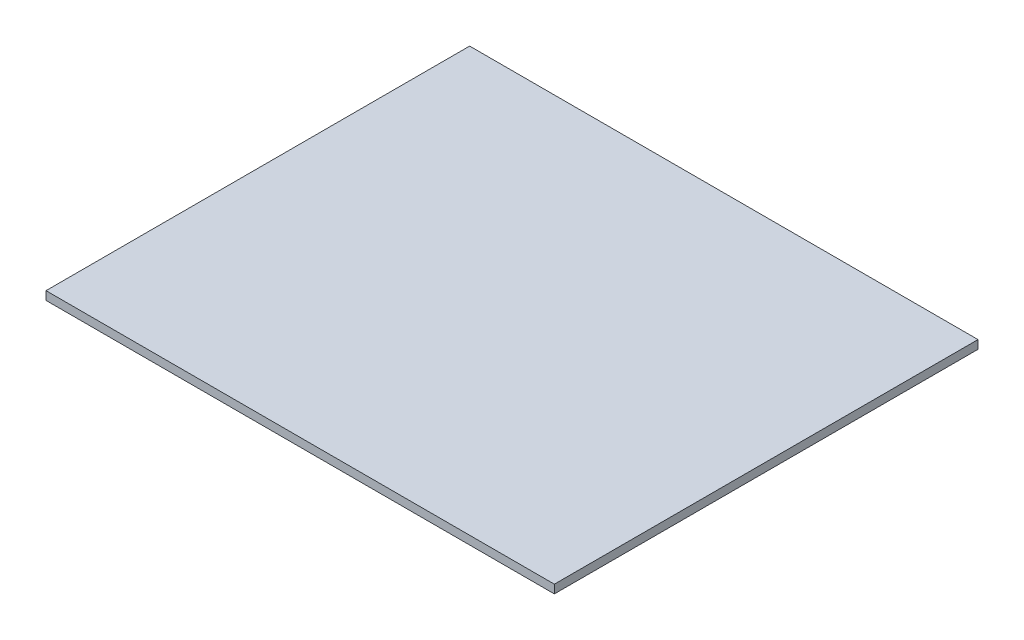
from build123d import *

# Parameters (mm, degrees)
SKETCH_1_W      = 1200
SKETCH_1_H      = 1000
EXTRUDE_1_DEPTH = 20


with BuildPart() as part:
    # 草图1 → 凸台-拉伸1 (new body)
    with BuildSketch(Plane(origin=(0, 0, 0), x_dir=(1, 0, 0), z_dir=(0, 1, 0))):
        with Locations((600, -500)):
            Rectangle(SKETCH_1_W, SKETCH_1_H)
    extrude(amount=EXTRUDE_1_DEPTH)


solid = part.part
